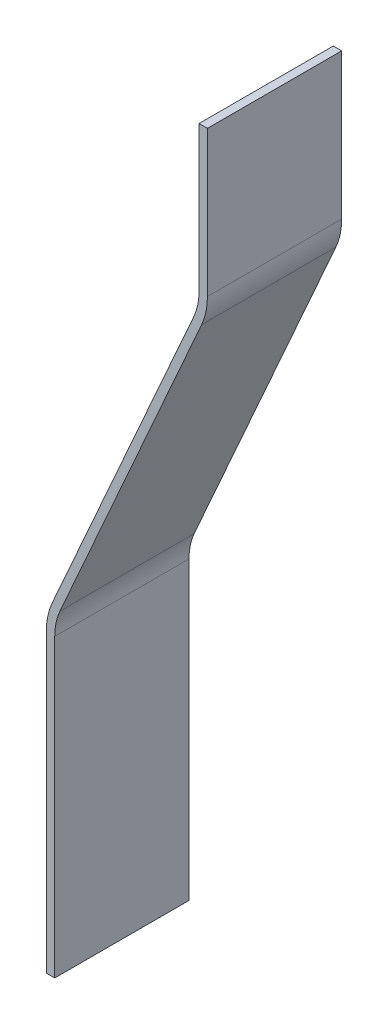
from build123d import *

# Parameters (mm, degrees)
BOSS_EXTRUDE1_DEPTH = 101.6


with BuildPart() as part:
    # Sketch1 → Boss-Extrude1 (new body)
    with BuildSketch(Plane.XY):
        with BuildLine():
            Line((0, -10.777235523), (0, -234.95))
            Line((0, -234.95), (6.35, -234.95))
            Line((6.35, -234.95), (6.35, -11.046666411))
            ThreePointArc((6.35, -11.046666411), (7.345399944, -1.558328843), (10.288256772, 7.516855153))
            Line((10.288256772, 7.516855153), (117.544159142, 248.92248269))
            ThreePointArc((117.544159142, 248.92248269), (120.814000062, 259.006020463), (121.92, 269.548617762))
            Line((121.92, 269.548617762), (121.92, 379.784617762))
            Line((121.92, 379.784617762), (115.57, 379.784617762))
            Line((115.57, 379.784617762), (115.57, 269.81804865))
            ThreePointArc((115.57, 269.81804865), (114.574600056, 260.329711081), (111.631743228, 251.254527086))
            Line((111.631743228, 251.254527086), (4.375840858, 9.848899548))
            ThreePointArc((4.375840858, 9.848899548), (1.105999938, -0.234638225), (0, -10.777235523))
        make_face()
    extrude(amount=BOSS_EXTRUDE1_DEPTH)


solid = part.part
